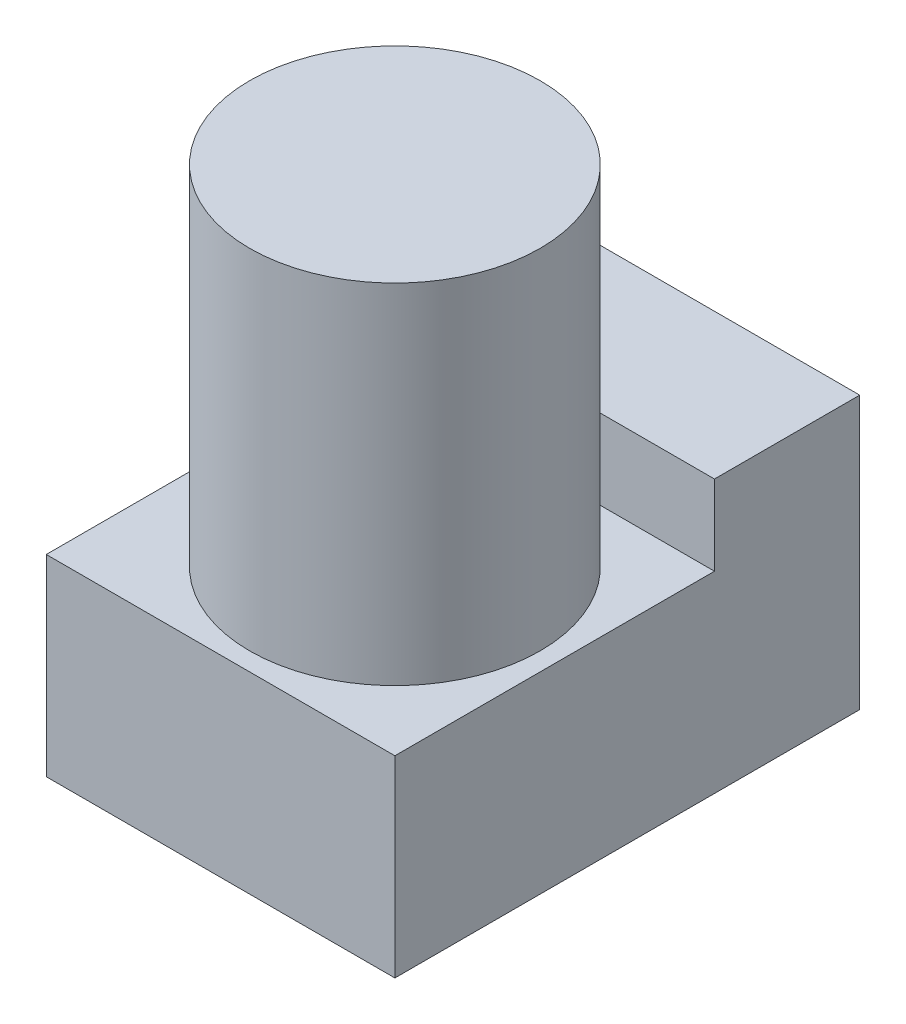
from build123d import *

# Parameters (mm, degrees)
BOSS_EXTRUDE1_DEPTH = 96
SKETCH2_R           = 40
BOSS_EXTRUDE2_DEPTH = 96


with BuildPart() as part:
    # Sketch1 → Boss-Extrude1 (new body)
    with BuildSketch(Plane(origin=(0, 0, 0), x_dir=(0, 0, -1), z_dir=(1, 0, 0))):
        Polygon((-101.449299301, -56.403624436), (26.550700699, -56.403624436), (26.550700699, -3.403624436), (26.550700699, 18.596375564), (-13.449299301, 18.596375564), (-13.449299301, -3.403624436), (-101.449299301, -3.403624436), align=None)
    extrude(amount=BOSS_EXTRUDE1_DEPTH)

    # Sketch2 → Boss-Extrude2 (add)
    with BuildSketch(Plane(origin=(0, -3.403624436, 0), x_dir=(1, 0, 0), z_dir=(0, 1, 0))):
        with Locations((51, -56.449299301)):
            Circle(SKETCH2_R)
    extrude(amount=BOSS_EXTRUDE2_DEPTH)


solid = part.part
